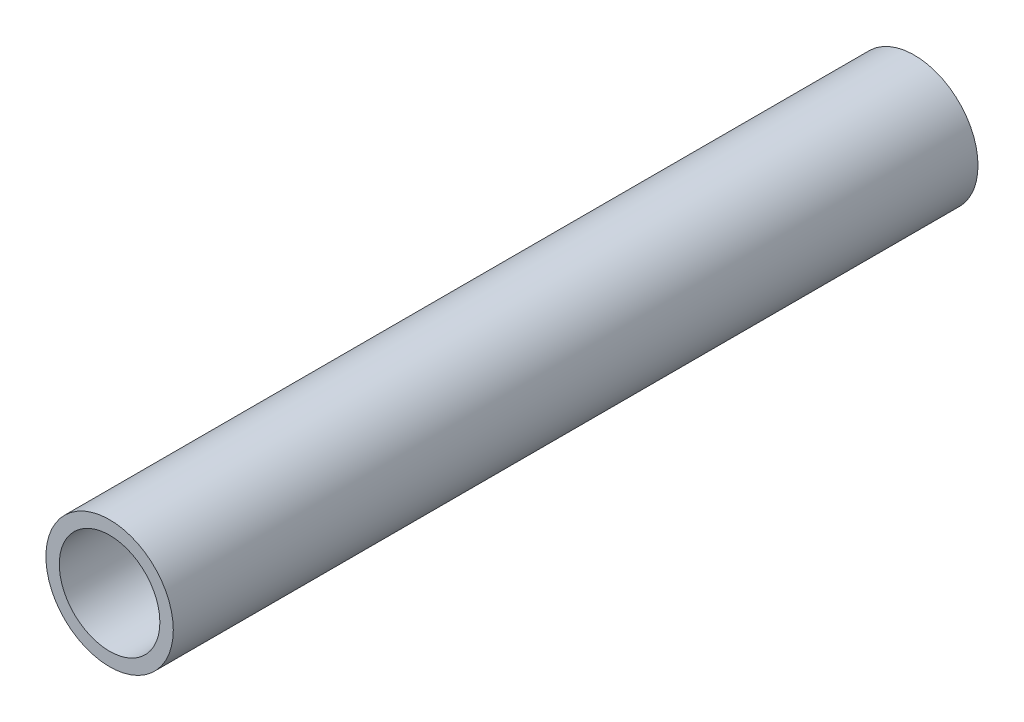
from build123d import *

# Parameters (mm, degrees)
PIPESKETCH_R    = 24.13
PIPESKETCH_R_2  = 19.05
EXTRUSION_DEPTH = 304.8


with BuildPart() as part:
    # PipeSketch → Extrusion (new body)
    with BuildSketch(Plane.XY):
        Circle(PIPESKETCH_R)
        Circle(PIPESKETCH_R_2, mode=Mode.SUBTRACT)
    extrude(amount=EXTRUSION_DEPTH)


solid = part.part
